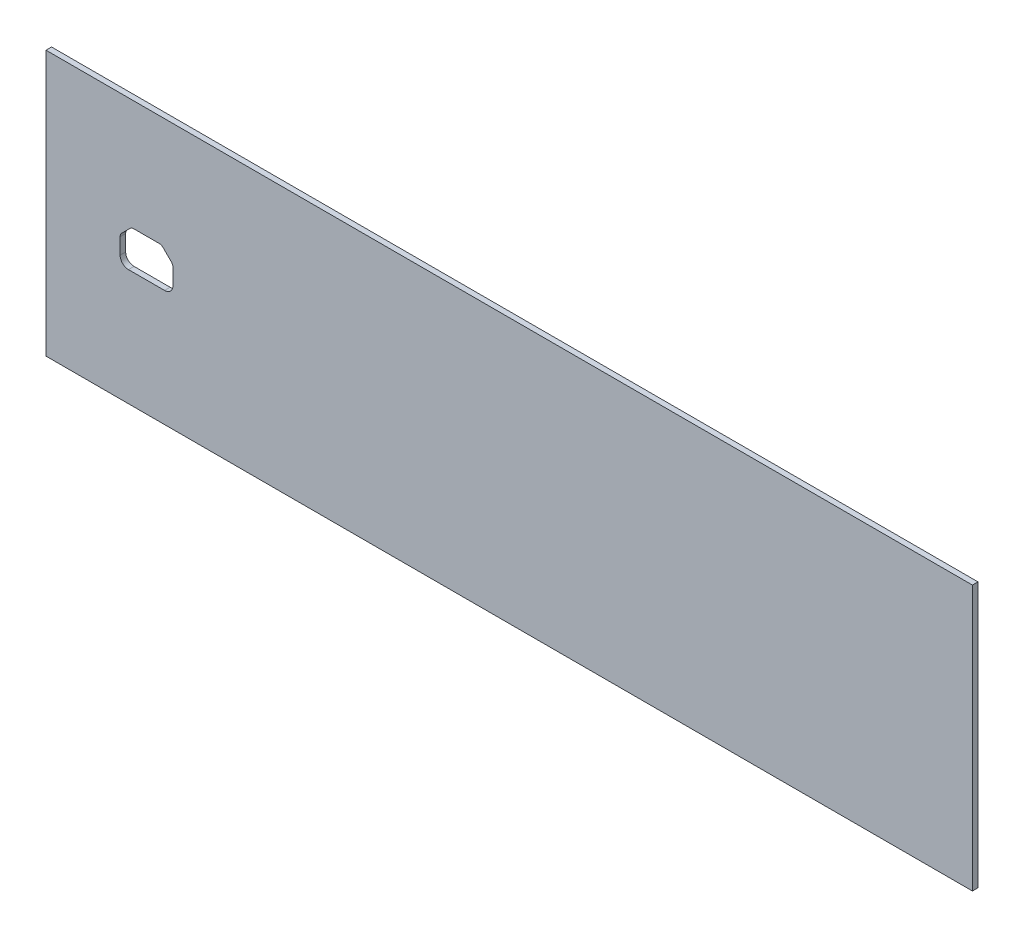
from build123d import *

# Parameters (mm, degrees)
BOSS_EXTRUDE1_DEPTH = 3
CUT_EXTRUDE2_DEPTH  = 3


with BuildPart() as part:
    # Sketch1 → Boss-Extrude1 (new body)
    with BuildSketch(Plane.XY):
        Polygon((-250, -71.5), (-250, 68.5), (-250, 71.5), (250, 71.5), (250, -71.5), align=None)
    extrude(amount=BOSS_EXTRUDE1_DEPTH)

    # Sketch2 → Cut-Extrude2 (cut)
    with BuildSketch(Plane.XY.offset(3)):
        with BuildLine():
            Line((-186.792893219, 10.828427125), (-182.378679656, 6.414213562))
            ThreePointArc((-182.378679656, 6.414213562), (-181.728361402, 5.440943516), (-181.5, 4.292893219))
            Line((-181.5, 4.292893219), (-181.5, -4.292893219))
            ThreePointArc((-181.5, -4.292893219), (-182.818019485, -7.474873734), (-186, -8.792893219))
            Line((-186, -8.792893219), (-205.5, -8.792893219))
            ThreePointArc((-205.5, -8.792893219), (-208.681980515, -7.474873734), (-210, -4.292893219))
            Line((-210, -4.292893219), (-210, 4.292893219))
            ThreePointArc((-210, 4.292893219), (-209.771638598, 5.440943516), (-209.121320344, 6.414213562))
            Line((-209.121320344, 6.414213562), (-204.707106781, 10.828427125))
            ThreePointArc((-204.707106781, 10.828427125), (-203.733836735, 11.478745379), (-202.585786438, 11.707106781))
            Line((-202.585786438, 11.707106781), (-188.914213562, 11.707106781))
            ThreePointArc((-188.914213562, 11.707106781), (-187.766163265, 11.478745379), (-186.792893219, 10.828427125))
        make_face()
    extrude(amount=-CUT_EXTRUDE2_DEPTH, mode=Mode.SUBTRACT)


solid = part.part
